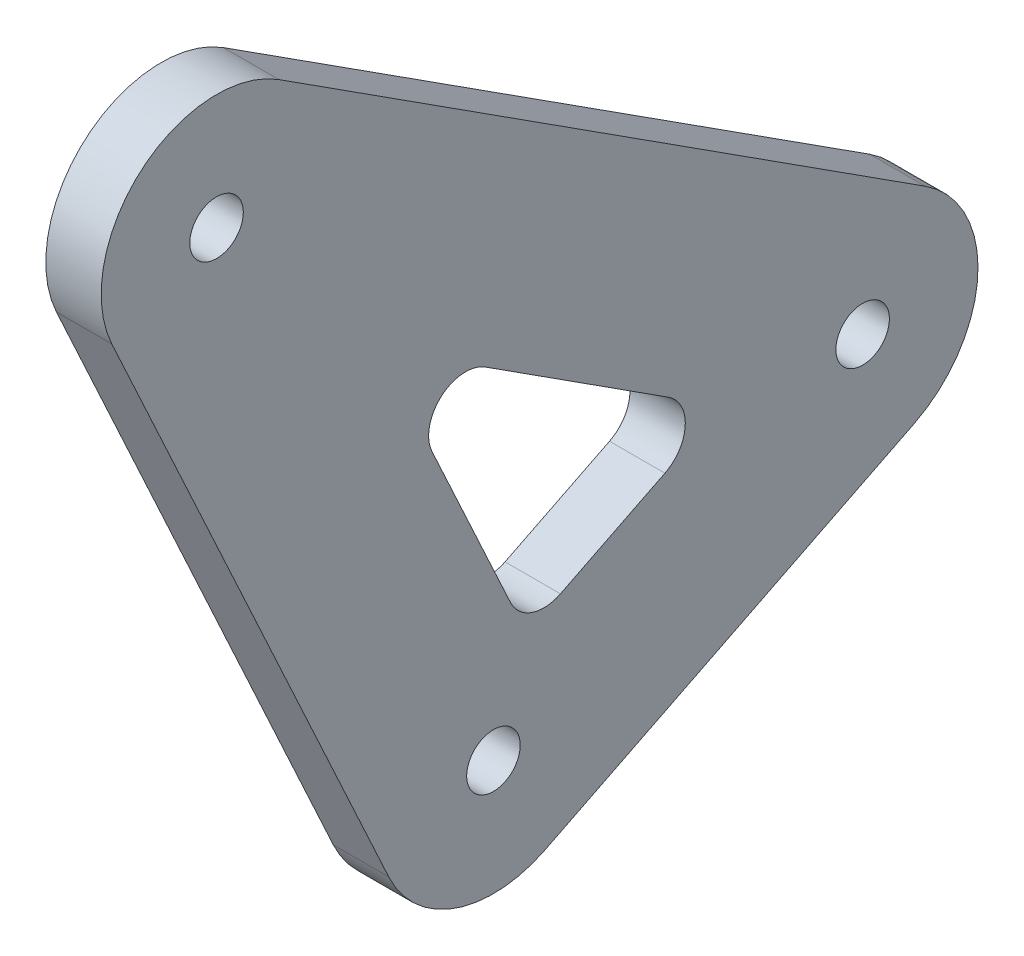
from build123d import *

# Parameters (mm, degrees)
SKETCH1_R           = 6.25
SKETCH1_R_2         = 1.45
BOSS_EXTRUDE1_DEPTH = 1.5
CUT_EXTRUDE1_DEPTH  = 3


with BuildPart() as part:
    # Sketch1 → Boss-Extrude1 (new body, symmetric)
    with BuildSketch(Plane(origin=(0, 0, 0), x_dir=(0, 0, -1), z_dir=(1, 0, 0))):
        with Locations((20, 10.000000011)):
            Circle(SKETCH1_R)
        with Locations((20, 10.000000011)):
            Circle(SKETCH1_R_2, mode=Mode.SUBTRACT)
        with BuildLine():
            ThreePointArc((-8.75, 32.5), (-13.659228479, 26.395507251), (-20.674746153, 29.880886391))
            Line((-20.674746153, 29.880886391), (-5.674746153, -2.619113609))
            ThreePointArc((-5.674746153, -2.619113609), (-1.340771521, 6.104492749), (6.25, 0))
            ThreePointArc((6.25, 0), (5.316567553, -3.28581945), (2.795084974, -5.590169942))
            Line((2.795084974, -5.590169942), (22.795084974, 4.409830069))
            ThreePointArc((22.795084974, 4.409830069), (13.759058052, 10.336368263), (23.379734945, 15.257365483))
            Line((23.379734945, 15.257365483), (-11.620265055, 37.757365472))
            ThreePointArc((-11.620265055, 37.757365472), (-9.514298431, 35.494925425), (-8.75, 32.5))
        make_face()
        Circle(SKETCH1_R)
        Circle(SKETCH1_R_2, mode=Mode.SUBTRACT)
        with Locations((-15, 32.5)):
            Circle(SKETCH1_R)
        with Locations((-15, 32.5)):
            Circle(SKETCH1_R_2, mode=Mode.SUBTRACT)
    extrude(amount=BOSS_EXTRUDE1_DEPTH, both=True)

    # Sketch2 → Cut-Extrude1 (cut)
    with BuildSketch(Plane(origin=(1.5, 0, 0), x_dir=(0, 0, -1), z_dir=(1, 0, 0))):
        with BuildLine():
            Line((3.629133347, 6.007194134), (9.288126649, 8.836690789))
            ThreePointArc((9.288126649, 8.836690789), (10.390800881, 10.51790733), (9.47521464, 12.307902121))
            Line((9.47521464, 12.307902121), (-0.428023639, 18.674269583))
            ThreePointArc((-0.428023639, 18.674269583), (-2.822182558, 18.500874667), (-3.32545759, 16.153796277))
            Line((-3.32545759, 16.153796277), (0.918787386, 6.957932161))
            ThreePointArc((0.918787386, 6.957932161), (2.072692273, 5.908791877), (3.629133347, 6.007194134))
        make_face()
    extrude(amount=-CUT_EXTRUDE1_DEPTH, mode=Mode.SUBTRACT)


solid = part.part
